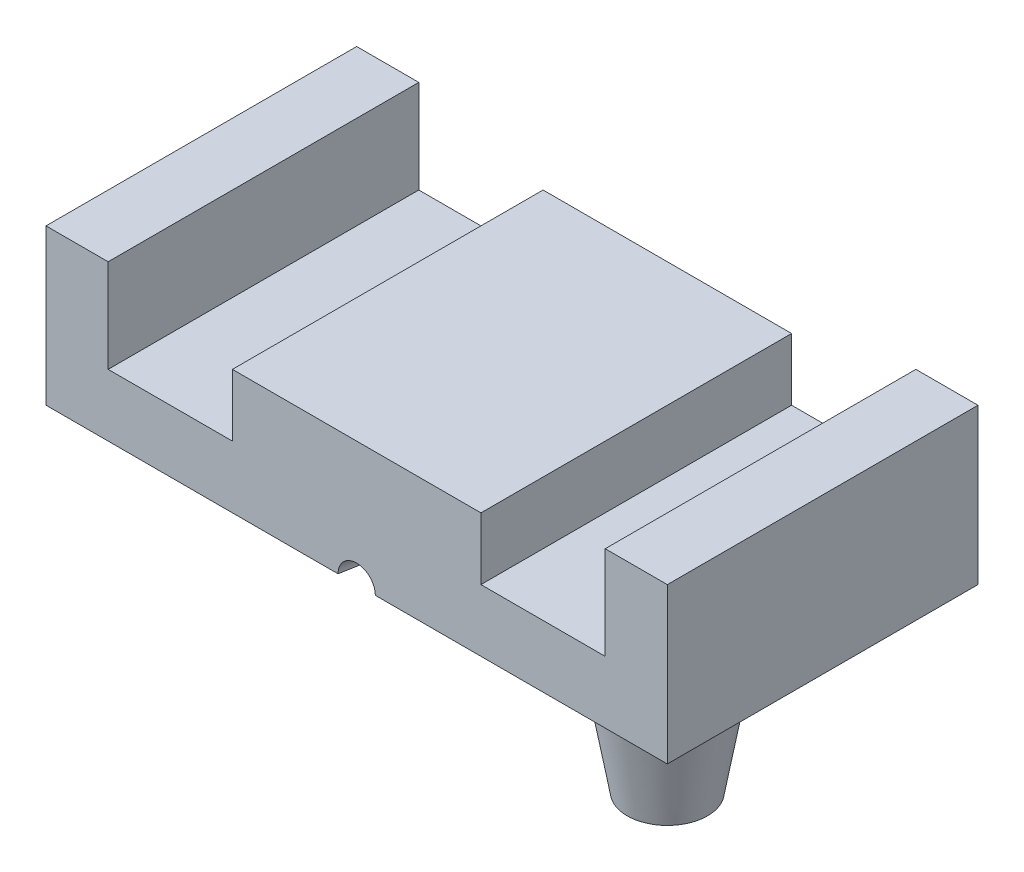
from build123d import *

# Parameters (mm, degrees)
ESQUISSE1_W             = 50
ESQUISSE1_H             = 25
BOSS_EXTRU_1_DEPTH      = 12.5
ESQUISSE2_R             = 5
BOSS_EXTRU_2_DEPTH      = 10
BOSS_EXTRU_2_TAPER      = 10
ESQUISSE4_R             = 5
BOSS_EXTRU_3_DEPTH      = 10
BOSS_EXTRU_3_TAPER      = 10
ENL_V_MAT_EXTRU_5_DEPTH = 26
ESQUISSE14_R            = 1.5
ENL_V_MAT_EXTRU_6_DEPTH = 4
ENL_V_MAT_EXTRU_6_TAPER = 10


with BuildPart() as part:
    # Esquisse1 → Boss.-Extru.1 (new body)
    with BuildSketch(Plane(origin=(0, 0, 0), x_dir=(1, 0, 0), z_dir=(0, 1, 0))):
        Rectangle(ESQUISSE1_W, ESQUISSE1_H)
    extrude(amount=-BOSS_EXTRU_1_DEPTH)

    # Esquisse2 → Boss.-Extru.2 (add)
    with BuildSketch(Plane.XZ.offset(12.5)):
        with Locations((17, 4.5)):
            Circle(ESQUISSE2_R)
    extrude(amount=BOSS_EXTRU_2_DEPTH, taper=BOSS_EXTRU_2_TAPER)

    # Esquisse4 → Boss.-Extru.3 (add)
    with BuildSketch(Plane.XZ.offset(12.5)):
        with Locations((-17, -4.5)):
            Circle(ESQUISSE4_R)
    extrude(amount=BOSS_EXTRU_3_DEPTH, taper=BOSS_EXTRU_3_TAPER)

    # Esquisse6 → Enlèvement de matière-Révolution1 (revolve, cut)
    with BuildSketch(Plane.XY):
        with BuildLine():
            Line((0, -20), (0, -5))
            ThreePointArc((0, -5), (-7.5, -12.5), (0, -20))
        make_face()
    revolve(axis=Axis((0, -20, 0), (0, 1, 0)), mode=Mode.SUBTRACT)

    # Esquisse8 → Enlèvement de matière-Révolution2 (revolve, cut)
    with BuildSketch(Plane.XY):
        with BuildLine():
            Line((8, -12.5), (10, -12.5))
            ThreePointArc((10, -12.5), (9, -11.5), (8, -12.5))
        make_face()
    revolve(axis=Axis((0, -20, 0), (0, 1, 0)), mode=Mode.SUBTRACT)

    # Esquisse13 → Enlèv. mat.-Extru.5 (cut, through all)
    with BuildSketch(Plane(origin=(0, 0, -12.5), x_dir=(-1, 0, 0), z_dir=(0, 0, -1))):
        Polygon((20, 0), (20, -7.5), (10, -7.5), (10, -2.5), (-10, -2.5), (-10, -7.5), (-20, -7.5), (-20, 0), align=None)
    extrude(amount=-ENL_V_MAT_EXTRU_5_DEPTH, mode=Mode.SUBTRACT)

    # Esquisse14 → Enlèv. mat.-Extru.6 (cut)
    with BuildSketch(Plane.XY.offset(12.5)):
        with Locations((0, -12.5)):
            Circle(ESQUISSE14_R)
    extrude(amount=-ENL_V_MAT_EXTRU_6_DEPTH, taper=ENL_V_MAT_EXTRU_6_TAPER, mode=Mode.SUBTRACT)


solid = part.part
